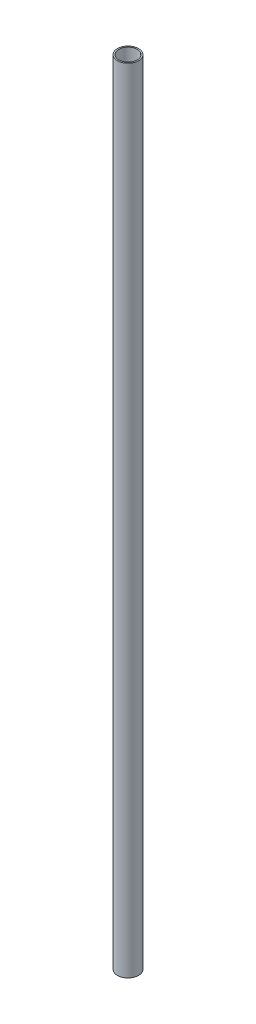
from build123d import *

# Parameters (mm, degrees)
SKETCH1_R           = 4
SKETCH1_R_2         = 3.5
BOSS_EXTRUDE1_DEPTH = 300


with BuildPart() as part:
    # Sketch1 → Boss-Extrude1 (new body)
    with BuildSketch(Plane(origin=(0, 0, 0), x_dir=(1, 0, 0), z_dir=(0, 1, 0))):
        Circle(SKETCH1_R)
        Circle(SKETCH1_R_2, mode=Mode.SUBTRACT)
    extrude(amount=BOSS_EXTRUDE1_DEPTH)


solid = part.part
